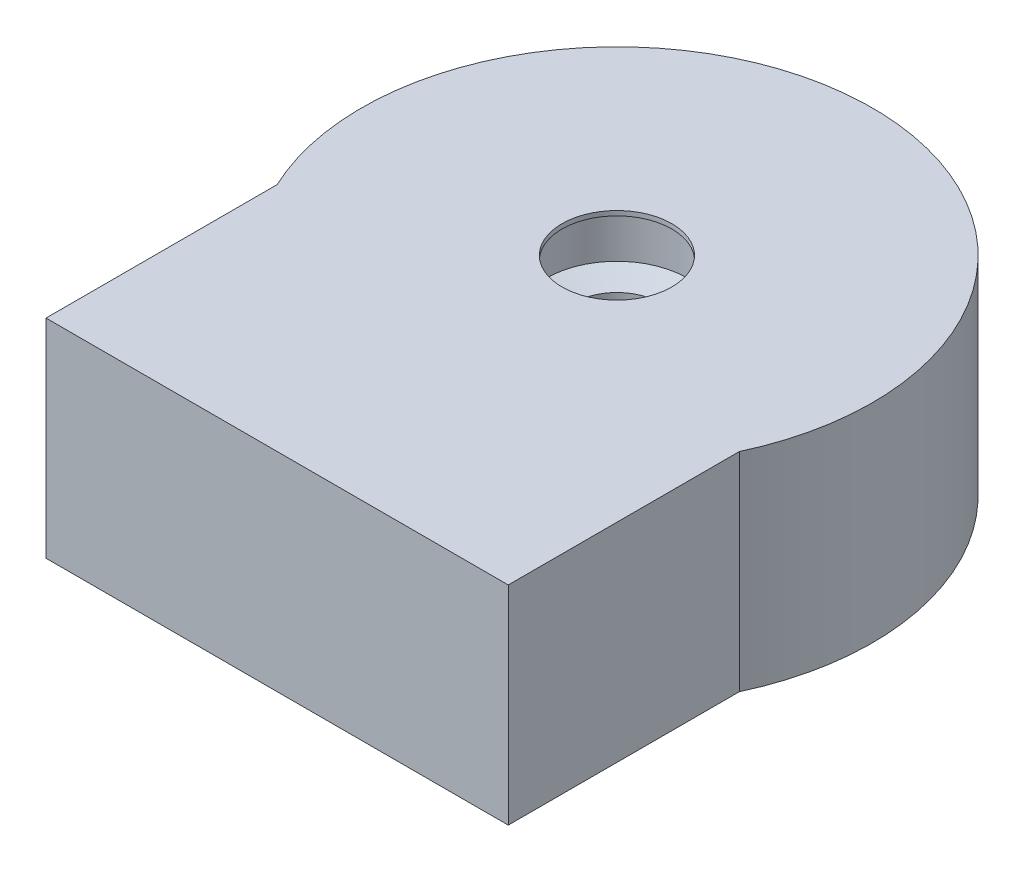
from build123d import *

# Parameters (mm, degrees)
SKETCH2_W           = 20
SKETCH2_H           = 10
BOSS_EXTRUDE1_DEPTH = 9


with BuildPart() as part:
    # Sketch1 → Revolve1 (revolve)
    with BuildSketch(Plane.XY):
        Polygon((11.05, 0), (2.375, 0), (2.375, -0.2), (3.05, -0.2), (3.05, -2.378460969), (1.85, -2.7), (1.85, -6.3), (1.15, -7), (0, -7), (0, -9), (11.05, -9), align=None)
    revolve(axis=Axis((0, 0, 0), (0, 1, 0)))

    # Sketch2 → Boss-Extrude1 (add)
    with BuildSketch(Plane(origin=(0, 0, 0), x_dir=(1, 0, 0), z_dir=(0, 1, 0))):
        with Locations((0, -9.701329599)):
            Rectangle(SKETCH2_W, SKETCH2_H)
    extrude(amount=-BOSS_EXTRUDE1_DEPTH)


solid = part.part
